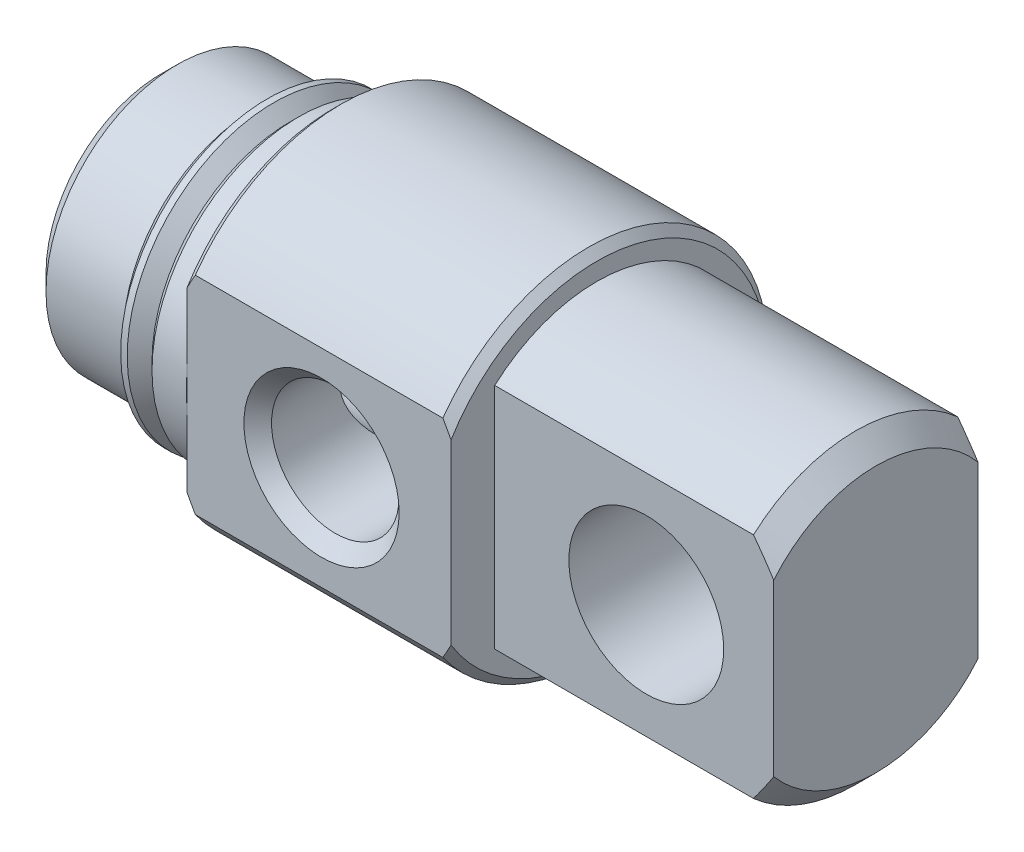
from build123d import *

# Parameters (mm, degrees)
SKETCH3_W               = 22.2504
SKETCH3_H               = 44.5008
SKETCH3_W_2             = 6.35
SKETCH3_H_2             = 22.2504
CUT_EXTRUDE1_DEPTH      = 8.6741
SKETCH4_W               = 5.5626
SKETCH4_H               = 11.1252
CUT_EXTRUDE2_DEPTH      = 8.2042
HOLE1_D                 = 3.96748
HOLE1_DEPTH             = 13.5509
HOLE1_TIP               = 1.145312823
HOLE2_D                 = 3.96748
HOLE2_DEPTH             = 4.5339
HOLE2_CSINK_D           = 4.826
HOLE2_CSINK_ANGLE       = 90
CUT_EXTRUDE3_DEPTH      = 4.7625
CUT_EXTRUDE3_DEPTH_BACK = 4.7625
SKETCH10_R              = 2.40665


with BuildPart() as part:
    # Sketch1 → Revolve1 (revolve)
    with BuildSketch(Plane.XY):
        Polygon((0, 0), (0, 3.57505), (0.508, 4.08305), (2.9083, 4.08305), (3.4671, 3.52425), (4.0259, 3.52425), (4.0259, 4.3053), (4.2799, 4.5593), (5.3467, 4.5593), (5.3467, 5.3086), (5.6007, 5.5626), (13.2969, 5.5626), (13.5509, 5.3086), (13.5509, 0), align=None)
    revolve(axis=Axis((13.5509, 0, 0), (-1, 0, 0)))

    # Sketch2 → Revolve2 (revolve)
    with BuildSketch(Plane.XY):
        Polygon((13.5509, 0), (13.5509, 4.7625), (21.59508, 4.7625), (22.225, 4.13258), (22.225, 0), align=None)
    revolve(axis=Axis((22.225, 0, 0), (-1, 0, 0)))

    # Sketch3 → Cut-Extrude1 (cut)
    with BuildSketch(Plane(origin=(22.225, 0, 0), x_dir=(0, 0, -1), z_dir=(1, 0, 0))):
        Rectangle(SKETCH3_W, SKETCH3_H)
        Rectangle(SKETCH3_W_2, SKETCH3_H_2, mode=Mode.SUBTRACT)
    extrude(amount=-CUT_EXTRUDE1_DEPTH, mode=Mode.SUBTRACT)

    # Sketch4 → Cut-Extrude2 (cut)
    with BuildSketch(Plane(origin=(13.5509, 0, 0), x_dir=(0, 0, -1), z_dir=(1, 0, 0))):
        with Locations((-7.3152, 0)):
            Rectangle(SKETCH4_W, SKETCH4_H)
    extrude(amount=-CUT_EXTRUDE2_DEPTH, mode=Mode.SUBTRACT)

    # Hole1
    with Locations(Plane.ZY):
        with Locations((0, 0)):
            Hole(HOLE1_D / 2, depth=HOLE1_DEPTH)
            with Locations((0, 0, -(HOLE1_DEPTH + HOLE1_TIP / 2))):  # 120° drill point
                Cone(0, HOLE1_D / 2, HOLE1_TIP, mode=Mode.SUBTRACT)

    # Hole2
    with Locations(Plane.XY.offset(4.5339)):
        with Locations((9.525, 0)):
            CounterSinkHole(HOLE2_D / 2, HOLE2_CSINK_D / 2, depth=HOLE2_DEPTH, counter_sink_angle=HOLE2_CSINK_ANGLE)

    # Sketch9 → Revolve3 (revolve)
    with BuildSketch(Plane.XY):
        with BuildLine():
            Line((3.306480735, 4.475131804), (3.912128708, 3.869483831))
            ThreePointArc((3.912128708, 3.869483831), (3.949326147, 3.779681269), (3.912128708, 3.689878708))
            Line((3.912128708, 3.689878708), (3.7465, 3.52425))
            Line((3.7465, 3.52425), (3.4671, 3.52425))
            Line((3.4671, 3.52425), (3.4671, 3.27025))
            Line((3.4671, 3.27025), (4.0259, 3.27025))
            Line((4.0259, 3.27025), (4.0259, 4.043080735))
            Line((4.0259, 4.043080735), (3.509680735, 4.5593))
            Line((3.509680735, 4.5593), (3.306480735, 4.5593))
            Line((3.306480735, 4.5593), (3.306480735, 4.475131804))
        make_face()
    revolve(axis=Axis((4.0259, 0, 0), (-1, 0, 0)))

    # Sketch10 → Cut-Extrude3 (cut, two sides: drawn at the far end of the back side and taken through both)
    with BuildSketch(Plane.XY.offset(-CUT_EXTRUDE3_DEPTH_BACK)):
        with Locations((18.2626, 0)):
            Circle(SKETCH10_R)
    extrude(amount=CUT_EXTRUDE3_DEPTH + CUT_EXTRUDE3_DEPTH_BACK, mode=Mode.SUBTRACT)


solid = part.part
